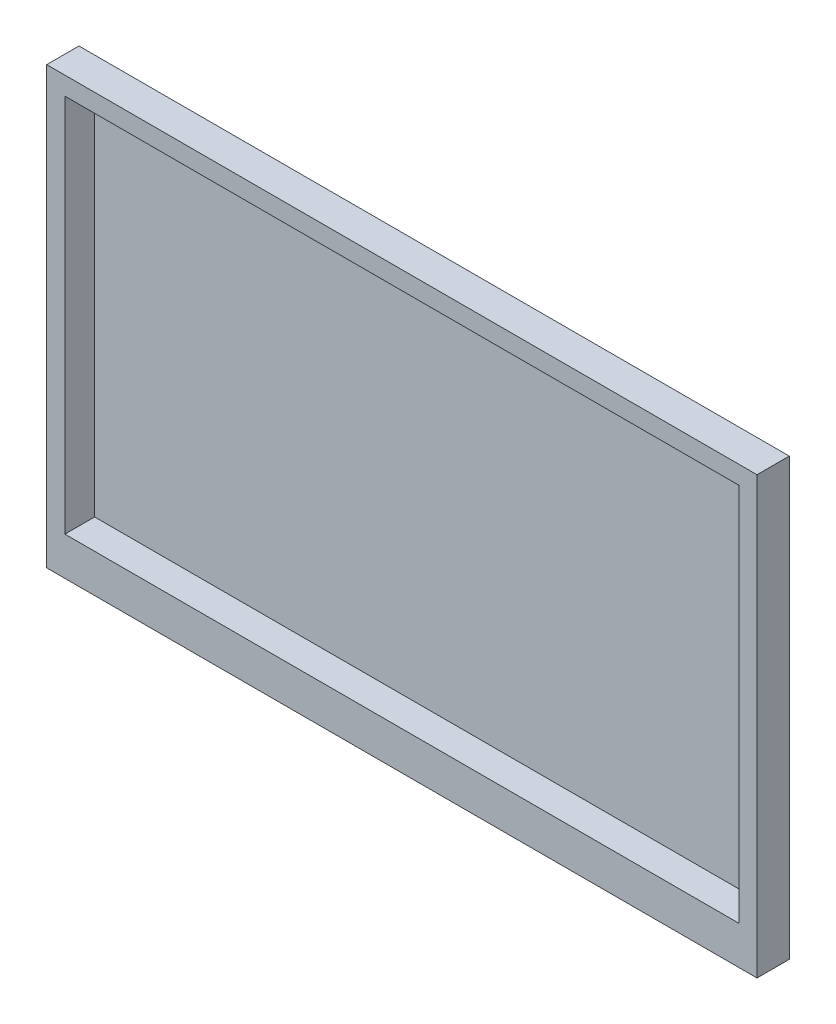
from build123d import *

# Parameters (mm, degrees)
SKETCH1_W           = 558.8
SKETCH1_H           = 342.9
SKETCH1_W_2         = 530.225
SKETCH1_H_2         = 298.45
BOSS_EXTRUDE1_DEPTH = 25.4
SKETCH2_W           = 530.225
SKETCH2_H           = 298.45
BOSS_EXTRUDE2_DEPTH = 2
SKETCH3_W           = 100
SKETCH3_H           = 100
BOSS_EXTRUDE3_DEPTH = 76.2


with BuildPart() as part:
    # Sketch1 → Boss-Extrude1 (new body)
    with BuildSketch(Plane.XY):
        Rectangle(SKETCH1_W, SKETCH1_H)
        with Locations((0, 7.9375)):
            Rectangle(SKETCH1_W_2, SKETCH1_H_2, mode=Mode.SUBTRACT)
    extrude(amount=-BOSS_EXTRUDE1_DEPTH)

    # Sketch2 → Boss-Extrude2 (add)
    with BuildSketch(Plane(origin=(0, 0, -25.4), x_dir=(-1, 0, 0), z_dir=(0, 0, -1))):
        with Locations((0, 7.9375)):
            Rectangle(SKETCH2_W, SKETCH2_H)
    extrude(amount=-BOSS_EXTRUDE2_DEPTH)

    # Sketch3 → Boss-Extrude3 (add)
    with BuildSketch(Plane(origin=(0, 0, -25.4), x_dir=(-1, 0, 0), z_dir=(0, 0, -1))):
        Rectangle(SKETCH3_W, SKETCH3_H)
    extrude(amount=BOSS_EXTRUDE3_DEPTH)


solid = part.part
